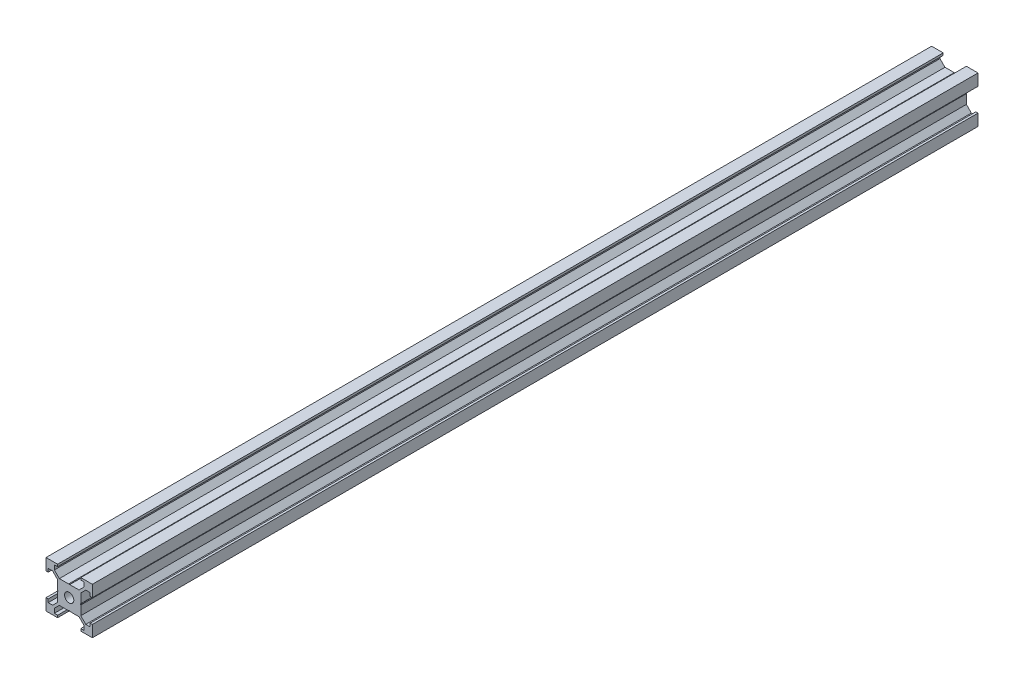
from build123d import *

# Parameters (mm, degrees)
SKETCH1_R           = 2
BOSS_EXTRUDE1_DEPTH = 382


with BuildPart() as part:
    # Sketch1 → Boss-Extrude1 (new body)
    with BuildSketch(Plane.XY):
        Polygon((6.4, 7.156263811), (4.243736189, 5), (5, 5), (5, 4.243736189), (7.156263811, 6.4), (9.056263811, 6.4), (9.056263811, 5), (10, 5), (10, 10), (5, 10), (5, 9.056263811), (6.4, 9.056263811), align=None)
        Polygon((-5, 0.245745613), (-5, 5), (-0.245745613, 5), (0, 4.827927069), (0.245745613, 5), (5, 5), (5, 0.245745613), (4.827927069, 0), (5, -0.245745613), (5, -5), (0.245745613, -5), (0, -4.827927069), (-0.245745613, -5), (-5, -5), (-5, -0.245745613), (-4.827927069, 0), align=None)
        Circle(SKETCH1_R, mode=Mode.SUBTRACT)
        Polygon((-10, 10), (-10, 5), (-9.056263811, 5), (-9.056263811, 6.4), (-7.156263811, 6.4), (-5, 4.243736189), (-5, 5), (-4.243736189, 5), (-6.4, 7.156263811), (-6.4, 9.056263811), (-5, 9.056263811), (-5, 10), align=None)
        Polygon((-5, -5), (-5, -4.243736189), (-7.156263811, -6.4), (-9.056263811, -6.4), (-9.056263811, -5), (-10, -5), (-10, -10), (-5, -10), (-5, -9.056263811), (-6.4, -9.056263811), (-6.4, -7.156263811), (-4.243736189, -5), align=None)
        Polygon((5, -5), (4.243736189, -5), (6.4, -7.156263811), (6.4, -9.056263811), (5, -9.056263811), (5, -10), (10, -10), (10, -5), (9.056263811, -5), (9.056263811, -6.4), (7.156263811, -6.4), (5, -4.243736189), align=None)
    extrude(amount=BOSS_EXTRUDE1_DEPTH)


solid = part.part
